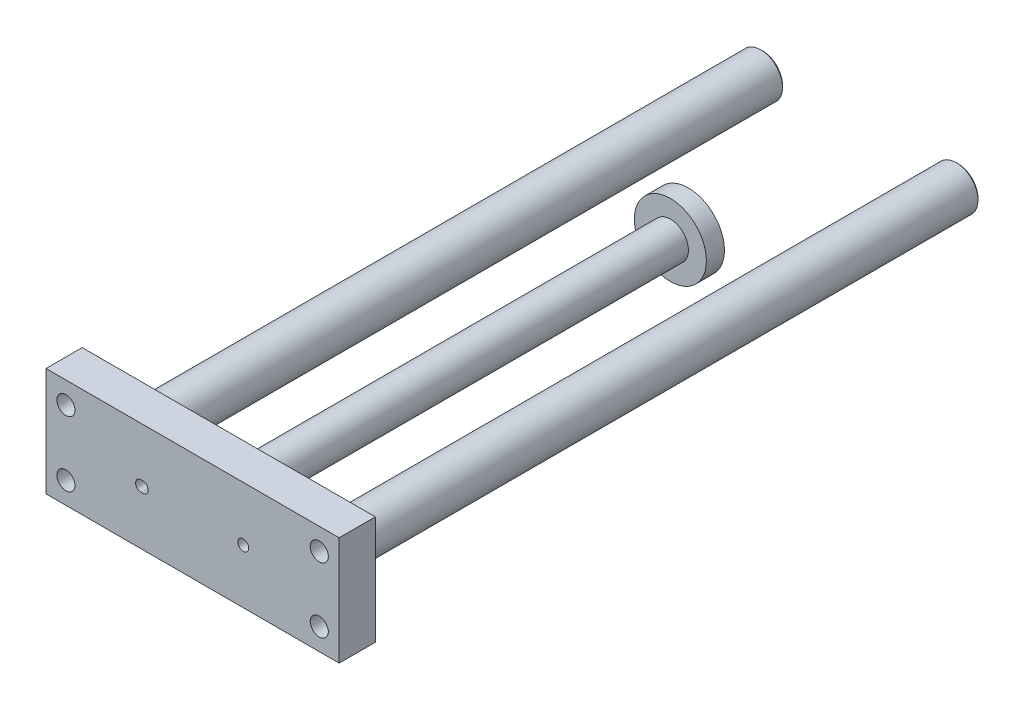
from build123d import *

# Parameters (mm, degrees)
SKETCH1_R           = 9.95
PISTON_DEPTH        = 5
SKETCH2_R           = 5
ROD_DEPTH           = 127
SKETCH3_W           = 81
SKETCH3_H           = 30
PLATE_DEPTH         = 10
SKETCH4_R           = 6
GUIDES_DEPTH        = 174.5
SKETCH5_R           = 1.5
MOUNTHOLES_DEPTH    = 6
CHAMFER1_SIZE       = 0.5
SKETCH6_R           = 2.5
MOUNTHOLES2_DEPTH   = 185.5
CUT_EXTRUDE1X_DEPTH = 3


with BuildPart() as part:
    # Sketch1 → Piston (new body)
    with BuildSketch(Plane.XY):
        Circle(SKETCH1_R)
    extrude(amount=PISTON_DEPTH)

    # Sketch2 → Rod (add)
    with BuildSketch(Plane.XY):
        Circle(SKETCH2_R)
    extrude(amount=ROD_DEPTH)

    # Sketch3 → Plate (add)
    with BuildSketch(Plane.XY.offset(127)):
        Rectangle(SKETCH3_W, SKETCH3_H)
    extrude(amount=PLATE_DEPTH)

    # Sketch4 → Guides (add)
    with BuildSketch(Plane(origin=(0, 0, 127), x_dir=(-1, 0, 0), z_dir=(0, 0, -1))):
        with Locations((-27, 0)):
            Circle(SKETCH4_R)
        with Locations((27, 0)):
            Circle(SKETCH4_R)
    extrude(amount=GUIDES_DEPTH)

    # Sketch5 → MountHoles (cut)
    with BuildSketch(Plane.XY.offset(137)):
        with Locations((14, 0)):
            Circle(SKETCH5_R)
        with Locations((-14, 0)):
            Circle(SKETCH5_R)
    extrude(amount=-MOUNTHOLES_DEPTH, mode=Mode.SUBTRACT)

    # Chamfer1
    chamfer1_edges = [part.edges().sort_by_distance(p)[0] for p in [
        (33, 0, -47.5),
        (-21, 0, -47.5),
    ]]
    chamfer(chamfer1_edges, length=CHAMFER1_SIZE)

    # Sketch6 → MountHoles2 (cut, through all)
    with BuildSketch(Plane.XY.offset(137)):
        with Locations((35, 9)):
            Circle(SKETCH6_R)
        with Locations((-35, 9)):
            Circle(SKETCH6_R)
        with Locations((35, -9)):
            Circle(SKETCH6_R)
        with Locations((-35, -9)):
            Circle(SKETCH6_R)
    extrude(amount=-MOUNTHOLES2_DEPTH, mode=Mode.SUBTRACT)

    # Sketch7 → Cut-Extrude1X (cut)
    with BuildSketch(Plane.XY.offset(137)):
        with BuildLine():
            Line((-14.25, 1.5), (-13.75, 1.5))
            ThreePointArc((-13.75, 1.5), (-12.25, 0), (-13.75, -1.5))
            Line((-13.75, -1.5), (-14.25, -1.5))
            ThreePointArc((-14.25, -1.5), (-15.75, 0), (-14.25, 1.5))
        make_face()
    extrude(amount=-CUT_EXTRUDE1X_DEPTH, mode=Mode.SUBTRACT)


solid = part.part
